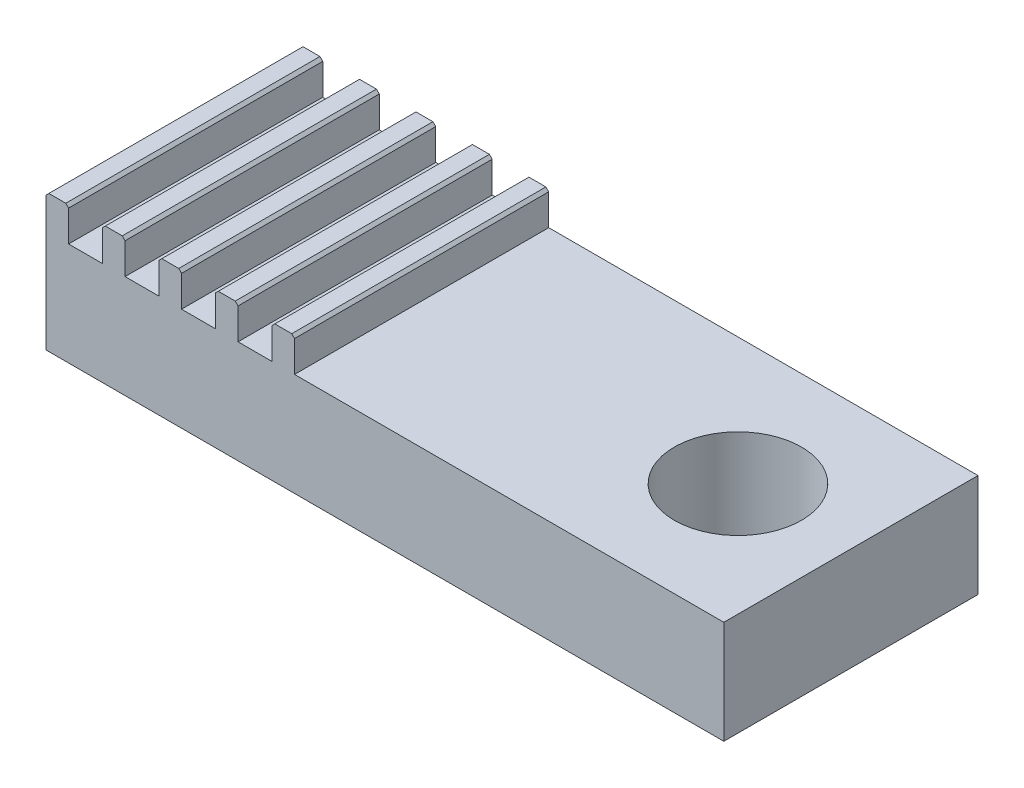
from build123d import *

# Parameters (mm, degrees)
BOSS_EXTRUDE1_DEPTH = 9
CHAMFER1_SIZE       = 0.1
SKETCH2_R           = 2.25
CUT_EXTRUDE1_DEPTH  = 4.65


with BuildPart() as part:
    # Sketch1 → Boss-Extrude1 (new body)
    with BuildSketch(Plane.XY):
        Polygon((28, 3.65), (28, 0), (4, 0), (4, 3.65), (4, 4.85), (4.8, 4.85), (4.8, 3.65), (6, 3.65), (6, 4.85), (6.8, 4.85), (6.8, 3.65), (8, 3.65), (8, 4.85), (8.8, 4.85), (8.8, 3.65), (10, 3.65), (10, 4.85), (10.8, 4.85), (10.8, 3.65), (12, 3.65), (12, 4.85), (12.8, 4.85), (12.8, 3.65), align=None)
    extrude(amount=BOSS_EXTRUDE1_DEPTH)

    # Chamfer1
    chamfer1_edges = [part.edges().sort_by_distance(p)[0] for p in [
        (4, 4.85, 4.5),
        (4.8, 4.85, 4.5),
        (6, 4.85, 4.5),
        (6.8, 4.85, 4.5),
        (8, 4.85, 4.5),
        (8.8, 4.85, 4.5),
        (10, 4.85, 4.5),
        (10.8, 4.85, 4.5),
        (12, 4.85, 4.5),
        (12.8, 4.85, 4.5),
    ]]
    chamfer(chamfer1_edges, length=CHAMFER1_SIZE)

    # Sketch2 → Cut-Extrude1 (cut, through all)
    with BuildSketch(Plane(origin=(0, 3.65, 0), x_dir=(1, 0, 0), z_dir=(0, 1, 0))):
        with Locations((24, -4.5)):
            Circle(SKETCH2_R)
    extrude(amount=-CUT_EXTRUDE1_DEPTH, mode=Mode.SUBTRACT)


solid = part.part
